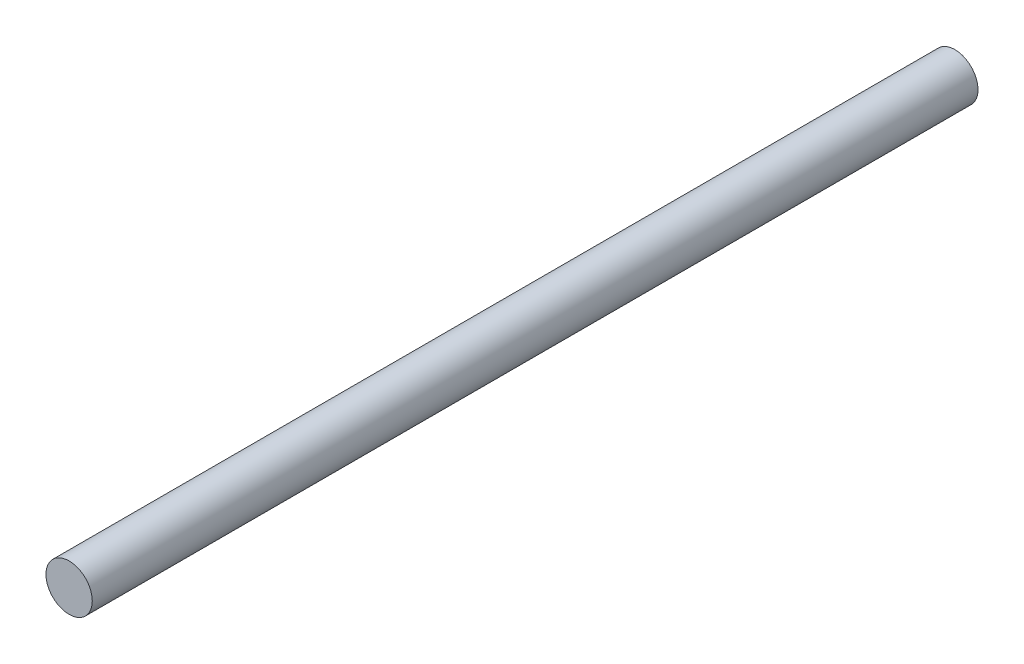
from build123d import *

# Parameters (mm, degrees)
SKETCH1_R           = 4
BOSS_EXTRUDE1_DEPTH = 153


with BuildPart() as part:
    # Sketch1 → Boss-Extrude1 (new body)
    with BuildSketch(Plane.XY):
        Circle(SKETCH1_R)
    extrude(amount=BOSS_EXTRUDE1_DEPTH)


solid = part.part
